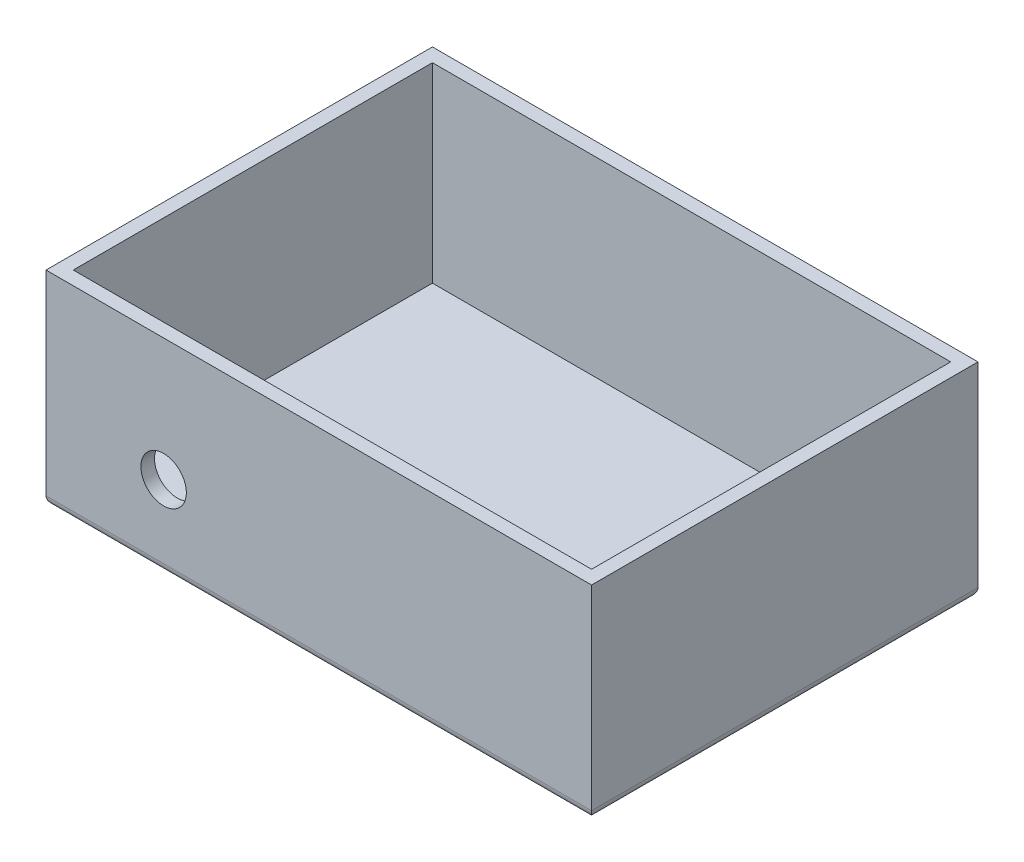
from build123d import *

# Parameters (mm, degrees)
SKETCH1_W           = 120
SKETCH1_H           = 85
BOSS_EXTRUDE1_DEPTH = 45
SHELL1_T            = -3
SKETCH5_R           = 5
CUT_EXTRUDE2_DEPTH  = 45
FILLET1_R           = 2


with BuildPart() as part:
    # Sketch1 → Boss-Extrude1 (new body)
    with BuildSketch(Plane(origin=(0, 0, 0), x_dir=(1, 0, 0), z_dir=(0, 1, 0))):
        Rectangle(SKETCH1_W, SKETCH1_H)
    extrude(amount=BOSS_EXTRUDE1_DEPTH)

    # Shell1
    shell1_openings = [part.faces().sort_by_distance(p)[0] for p in [
        (0, 45, 0),
    ]]
    offset(amount=SHELL1_T, openings=shell1_openings, kind=Kind.INTERSECTION)

    # Sketch5 → Cut-Extrude2 (cut)
    with BuildSketch(Plane(origin=(0, 0, 39.5), x_dir=(-1, 0, 0), z_dir=(0, 0, -1))):
        with Locations((34.130287034, 18)):
            Circle(SKETCH5_R)
    extrude(amount=-CUT_EXTRUDE2_DEPTH, mode=Mode.SUBTRACT)

    # Fillet1
    fillet1_edges = [part.edges().sort_by_distance(p)[0] for p in [
        (0, 0, -42.5),
        (60, 0, 0),
        (0, 0, 42.5),
        (-60, 0, 0),
    ]]
    fillet(fillet1_edges, radius=FILLET1_R)


solid = part.part
